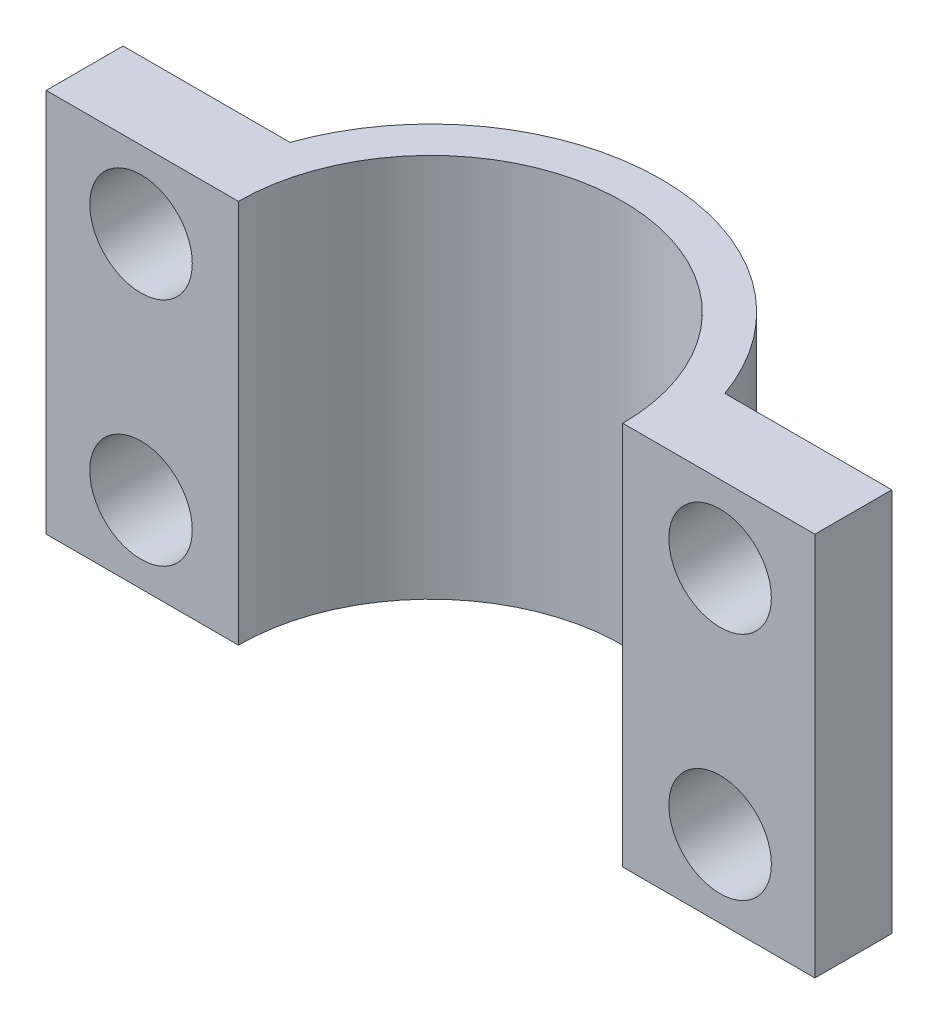
from build123d import *

# Parameters (mm, degrees)
SKETCH1_W           = 30
SKETCH1_H           = 15
BOSS_EXTRUDE1_DEPTH = 15
SKETCH2_R           = 7.5
CUT_EXTRUDE1_DEPTH  = 15
CUT_EXTRUDE2_REACH  = 5
SKETCH3_R           = 2


with BuildPart() as part:
    # Sketch1 → Boss-Extrude1 (new body)
    with BuildSketch(Plane.XY):
        Rectangle(SKETCH1_W, SKETCH1_H)
    extrude(amount=BOSS_EXTRUDE1_DEPTH)

    # Sketch2 → Cut-Extrude1 (cut)
    with BuildSketch(Plane.XZ.offset(7.5)):
        with Locations((0, 15)):
            Circle(SKETCH2_R)
        with BuildLine():
            Line((-15, 12), (-9, 12))
            Line((-9, 12), (-8.485281374, 12))
            ThreePointArc((-8.485281374, 12), (0, 6), (8.485281374, 12))
            Line((8.485281374, 12), (9, 12))
            Line((9, 12), (15, 12))
            Line((15, 12), (15, 0))
            Line((15, 0), (11, 0))
            Line((11, 0), (-11, 0))
            Line((-11, 0), (-15, 0))
            Line((-15, 0), (-15, 12))
        make_face()
    extrude(amount=-CUT_EXTRUDE1_DEPTH, mode=Mode.SUBTRACT)

    # Sketch3 → Cut-Extrude2 (cut, up to next)
    with BuildSketch(Plane(origin=(0, 0, 12), x_dir=(-1, 0, 0), z_dir=(0, 0, -1)), mode=Mode.PRIVATE) as cut_extrude2_sk1:
        with Locations((11.3, -4.5)):
            Circle(SKETCH3_R)
    cut_extrude2_tool1 = extrude(cut_extrude2_sk1.sketch, amount=-CUT_EXTRUDE2_REACH, mode=Mode.PRIVATE) & part.part
    add(cut_extrude2_tool1.solids().sort_by_distance((-11.3, -4.5, 12))[0], mode=Mode.SUBTRACT)
    # Sketch3 → Cut-Extrude2 (cut, up to next)
    with BuildSketch(Plane(origin=(0, 0, 12), x_dir=(-1, 0, 0), z_dir=(0, 0, -1)), mode=Mode.PRIVATE) as cut_extrude2_sk2:
        with Locations((11.3, 4.5)):
            Circle(SKETCH3_R)
    cut_extrude2_tool2 = extrude(cut_extrude2_sk2.sketch, amount=-CUT_EXTRUDE2_REACH, mode=Mode.PRIVATE) & part.part
    add(cut_extrude2_tool2.solids().sort_by_distance((-11.3, 4.5, 12))[0], mode=Mode.SUBTRACT)
    # Sketch3 → Cut-Extrude2 (cut, up to next)
    with BuildSketch(Plane(origin=(0, 0, 12), x_dir=(-1, 0, 0), z_dir=(0, 0, -1)), mode=Mode.PRIVATE) as cut_extrude2_sk3:
        with Locations((-11.3, 4.5)):
            Circle(SKETCH3_R)
    cut_extrude2_tool3 = extrude(cut_extrude2_sk3.sketch, amount=-CUT_EXTRUDE2_REACH, mode=Mode.PRIVATE) & part.part
    add(cut_extrude2_tool3.solids().sort_by_distance((11.3, 4.5, 12))[0], mode=Mode.SUBTRACT)
    # Sketch3 → Cut-Extrude2 (cut, up to next)
    with BuildSketch(Plane(origin=(0, 0, 12), x_dir=(-1, 0, 0), z_dir=(0, 0, -1)), mode=Mode.PRIVATE) as cut_extrude2_sk4:
        with Locations((-11.3, -4.5)):
            Circle(SKETCH3_R)
    cut_extrude2_tool4 = extrude(cut_extrude2_sk4.sketch, amount=-CUT_EXTRUDE2_REACH, mode=Mode.PRIVATE) & part.part
    add(cut_extrude2_tool4.solids().sort_by_distance((11.3, -4.5, 12))[0], mode=Mode.SUBTRACT)


solid = part.part
